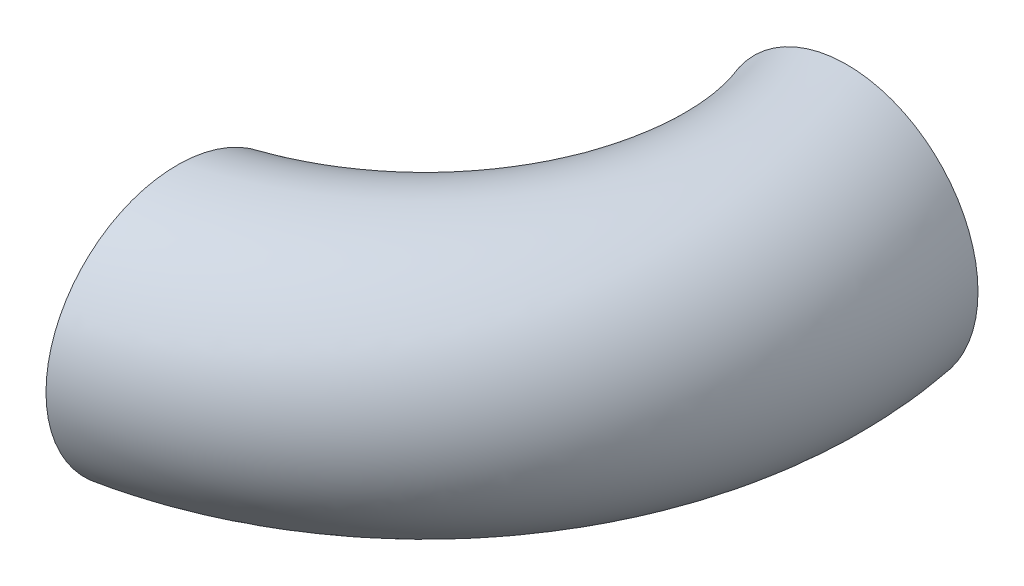
from build123d import *

# Parameters (mm, degrees)
SKETCH1_R   = 28.702
SKETCH1_R_2 = 24.13


with BuildPart() as part:
    # Sweep2: sweep along a path in Sketch2
    with BuildLine(Plane(origin=(0, 0, 0), x_dir=(1, 0, 0), z_dir=(0, 1, 0))) as sweep2_path:
        ThreePointArc((-73.261661461, 0), (-59.79127728, -5.579615818), (-54.211661461, -19.05))
    # Sketch1 → Sweep2 (sweep)
    with BuildSketch(Plane.XY):
        Circle(SKETCH1_R)
        Circle(SKETCH1_R_2, mode=Mode.SUBTRACT)
    sweep(path=sweep2_path.line)


solid = part.part
